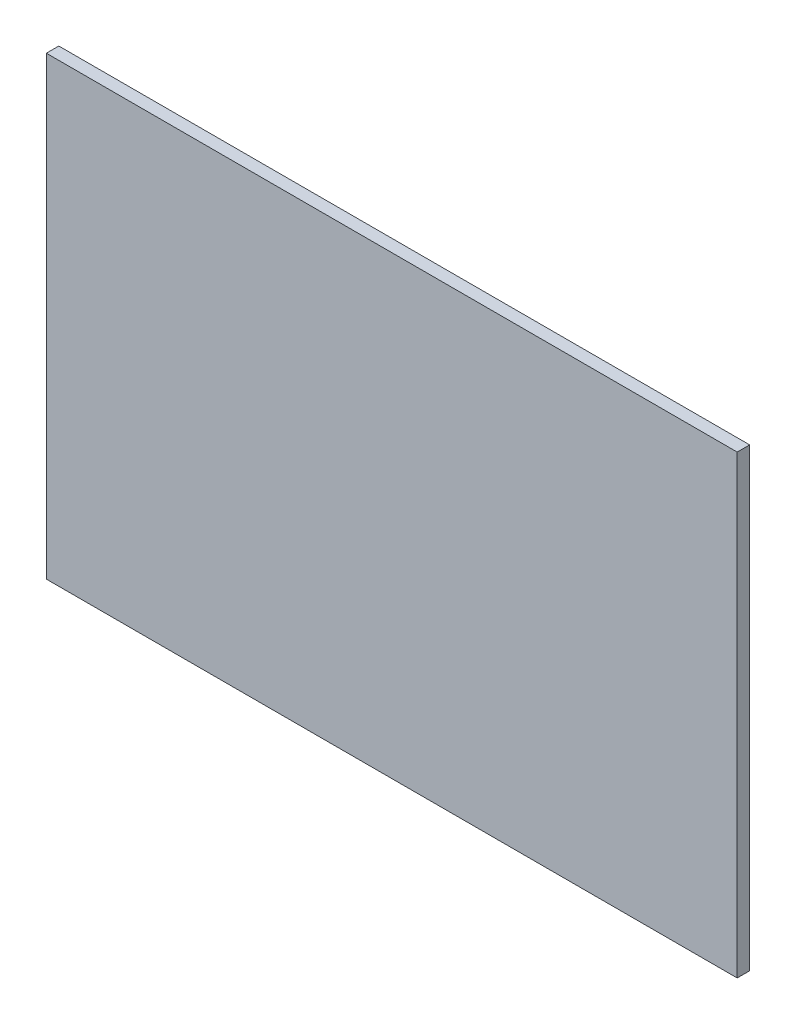
from build123d import *

# Parameters (mm, degrees)
SKETCH1_W           = 14.224
SKETCH1_H           = 14.732
SKETCH1_W_2         = 13.335
SKETCH1_H_2         = 17.78
BOSS_EXTRUDE1_DEPTH = 1.65


with BuildPart() as part:
    # Sketch1 → Boss-Extrude1 (new body)
    with BuildSketch(Plane.XY):
        Polygon((13.335, 1.905), (0, 1.905), (0, 0), (91.5, 0), (91.5, 36.195), (78.165, 36.195), (78.165, 53.975), (91.5, 53.975), (91.5, 60.325), (0, 60.325), (0, 57.531), (14.224, 57.531), (14.224, 42.799), (0, 42.799), (0, 39.37), (13.335, 39.37), (13.335, 21.59), (0, 21.59), (0, 19.685), (13.335, 19.685), align=None)
        with Locations((7.112, 50.165)):
            Rectangle(SKETCH1_W, SKETCH1_H)
        with Locations((6.6675, 30.48)):
            Rectangle(SKETCH1_W_2, SKETCH1_H_2)
        with Locations((6.6675, 10.795)):
            Rectangle(SKETCH1_W_2, SKETCH1_H_2)
        with Locations((84.8325, 45.085)):
            Rectangle(SKETCH1_W_2, SKETCH1_H_2)
    extrude(amount=BOSS_EXTRUDE1_DEPTH)


solid = part.part
